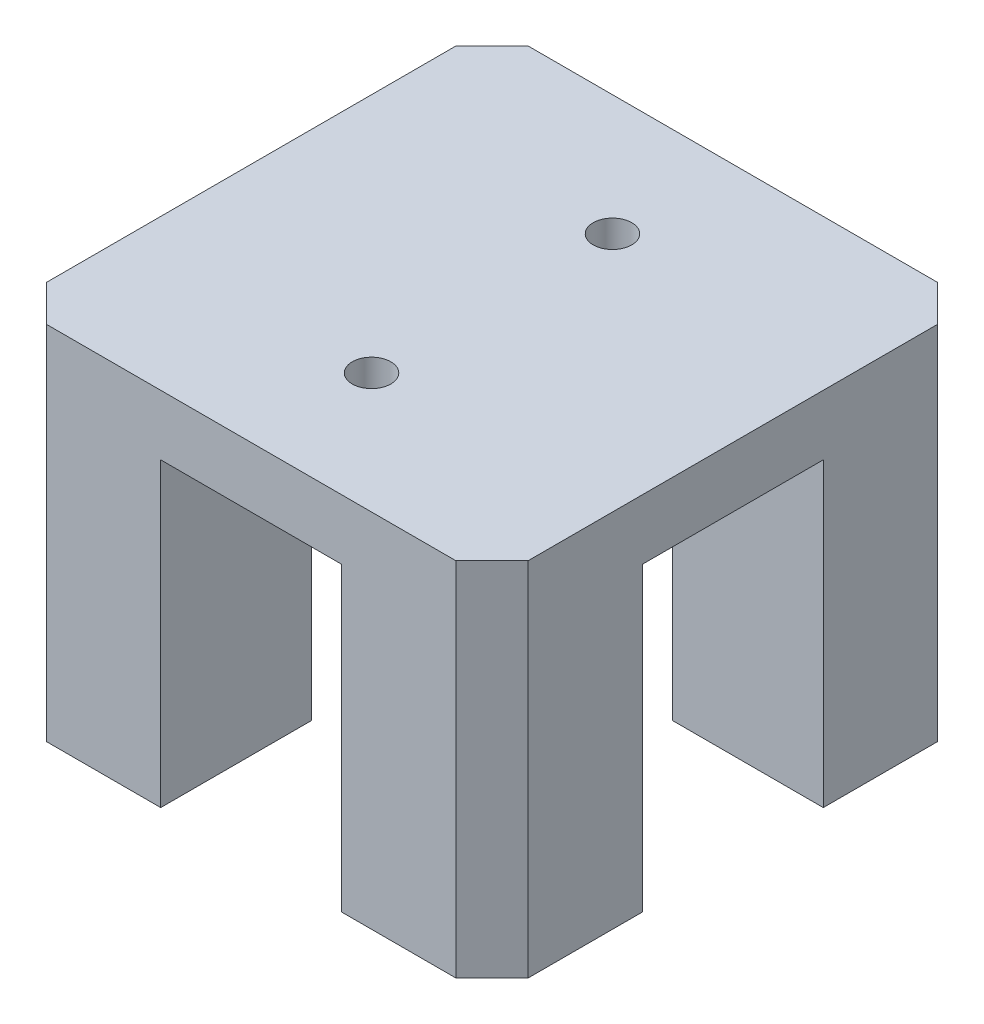
from build123d import *

# Parameters (mm, degrees)
SKIZZE1_W                       = 40
SKIZZE1_H                       = 40
AUFSATZ_LINEAR_AUSTRAGEN1_DEPTH = 30
FASE1_SIZE                      = 3
SCHNITT_LINEAR_AUSTRAGEN1_DEPTH = 25
DURCHGANGSLOCH_F_R_M31_D        = 3.2


with BuildPart() as part:
    # Skizze1 → Aufsatz-Linear austragen1 (new body)
    with BuildSketch(Plane(origin=(0, 0, 0), x_dir=(1, 0, 0), z_dir=(0, 1, 0))):
        Rectangle(SKIZZE1_W, SKIZZE1_H)
    extrude(amount=AUFSATZ_LINEAR_AUSTRAGEN1_DEPTH)

    # Fase1
    fase1_edges = [part.edges().sort_by_distance(p)[0] for p in [
        (-20, 15, -20),
        (20, 15, -20),
        (20, 15, 20),
        (-20, 15, 20),
    ]]
    chamfer(fase1_edges, length=FASE1_SIZE)

    # Skizze2 → Schnitt-Linear austragen1 (cut)
    with BuildSketch(Plane.XZ):
        Polygon((-20, 7.5), (-7.5, 7.5), (-7.5, 20), (7.5, 20), (7.5, 7.5), (20, 7.5), (20, -7.5), (7.5, -7.5), (7.5, -20), (-7.5, -20), (-7.5, -7.5), (-20, -7.5), align=None)
    extrude(amount=-SCHNITT_LINEAR_AUSTRAGEN1_DEPTH, mode=Mode.SUBTRACT)

    # Durchgangsloch für M31 (through all)
    with Locations(Plane(origin=(0, 30, 0), x_dir=(1, 0, 0), z_dir=(0, 1, 0))):
        with Locations((0, 10), (0, -10)):
            Hole(DURCHGANGSLOCH_F_R_M31_D / 2)


solid = part.part
